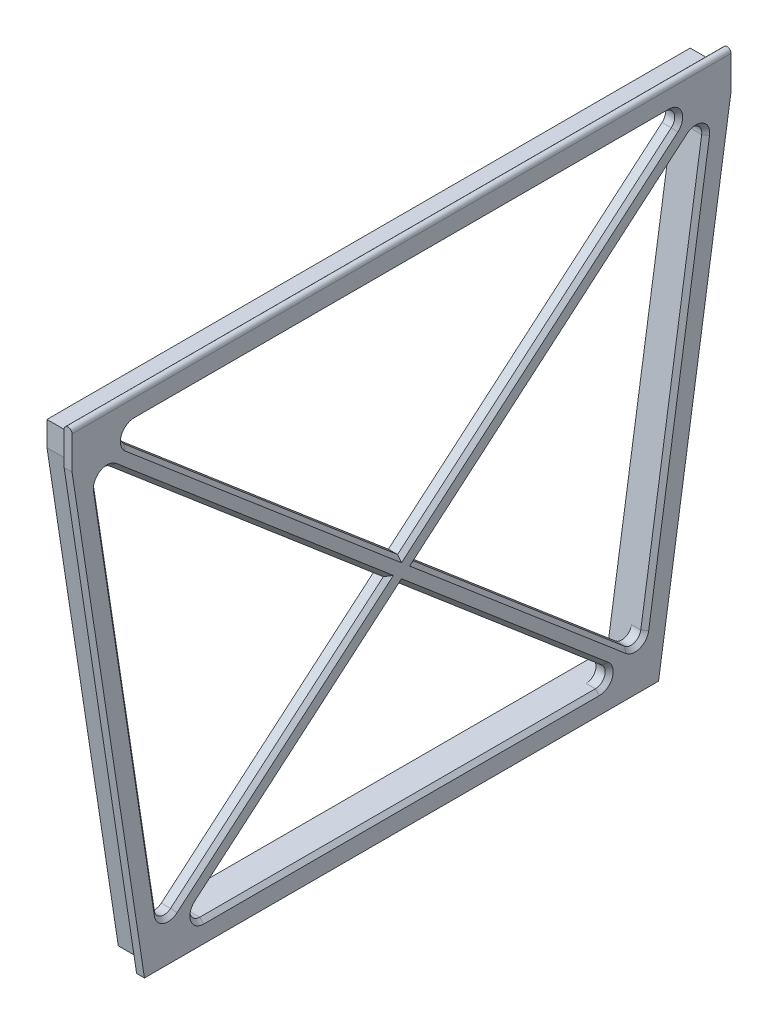
from build123d import *

# Parameters (mm, degrees)
EXTRUDE_THIN1_DEPTH          = 5
EXTRUDE_THIN2_DEPTH          = 2
CUT_EXTRUDE_THIN1_DEPTH      = 1
CUT_EXTRUDE_THIN1_DEPTH_BACK = 3.8
BOSS_EXTRUDE1_DEPTH          = 100
FILLET1_R                    = 1.5
CHAMFER1_SIZE                = 0.6


with BuildPart() as part:
    # Sketch1 → Extrude-Thin1 (new body)
    with BuildSketch(Plane(origin=(0, 0, 0), x_dir=(0, 0, -1), z_dir=(1, 0, 0))):
        Polygon((50, 77), (-50, 77), (-50, 72), (-39, 0), (39, 0), (50, 72), align=None)
        Polygon((46.8, 73.8), (-46.8, 73.8), (-46.8, 72.243034455), (-36.251758625, 3.2), (36.251758625, 3.2), (46.8, 72.243034455), align=None, mode=Mode.SUBTRACT)
    extrude(amount=EXTRUDE_THIN1_DEPTH)

    # Sketch3 → Extrude-Thin2 (add)
    with BuildSketch(Plane(origin=(5, 0, 0), x_dir=(0, 0, -1), z_dir=(1, 0, 0))):
        Polygon((-47.706752564, 72.733323016), (35.345006061, 2.133323016), (37.158511189, 4.266676984), (-45.893247436, 74.866676984), align=None)
        Polygon((45.893247436, 74.866676984), (-37.158511189, 4.266676984), (-35.345006061, 2.133323016), (47.706752564, 72.733323016), align=None)
    extrude(amount=-EXTRUDE_THIN2_DEPTH)

    # Sketch4 → Cut-Extrude-Thin1 (cut, two sides)
    with BuildSketch(Plane.ZY) as cut_extrude_thin1_sk:
        Polygon((50, 77), (50, 72), (39, 0), (-39, 0), (-50, 72), (-50, 77), align=None)
        Polygon((48.8, 75.8), (48.8, 72.091137921), (37.969409484, 1.2), (-37.969409484, 1.2), (-48.8, 72.091137921), (-48.8, 75.8), align=None, mode=Mode.SUBTRACT)
    extrude(amount=CUT_EXTRUDE_THIN1_DEPTH, mode=Mode.SUBTRACT)
    extrude(cut_extrude_thin1_sk.sketch, amount=-CUT_EXTRUDE_THIN1_DEPTH_BACK, mode=Mode.SUBTRACT)

    # Sketch5 → Boss-Extrude1 (add)
    with BuildSketch(Plane(origin=(0, 0, -50), x_dir=(-1, 0, 0), z_dir=(0, 0, -1))):
        with BuildLine():
            Line((-5, 77), (-3.8, 77))
            ThreePointArc((-3.8, 77), (-4.4, 77.6), (-5, 77))
        make_face()
    extrude(amount=-BOSS_EXTRUDE1_DEPTH)

    # Fillet1
    fillet1_edges = [part.edges().sort_by_distance(p)[0] for p in [
        (4, 73.8, -44.638440079),
        (4, 73.8, 44.638440079),
        (4, 71.92064886, -46.750746645),
        (4, 4.826274454, -36.500217222),
        (4, 3.2, 34.090198704),
        (4, 3.2, -34.090198704),
        (4, 4.826274454, 36.500217222),
        (4, 71.92064886, 46.750746645),
    ]]
    fillet(fillet1_edges, radius=FILLET1_R)

    # Chamfer1
    chamfer1_edges = [part.edges().sort_by_distance(p)[0] for p in [
        (5, 37.716457047, 41.525106229),
        (5, 3.2, 0),
        (5, 51.667563114, 22.92561366),
        (5, 73.8, 0),
        (5, 53.505615047, 20.764723924),
        (5, 37.716457047, -41.525106229),
        (5, 51.667563114, -22.92561366),
        (5, 53.505615047, -20.764723924),
        (5, 6.30509587, 35.948092357),
        (5, 4.18245884, 31.417574766),
        (5, 69.485539395, 45.392056481),
        (5, 72.81754116, 41.965816141),
        (5, 69.485539395, -45.392056481),
        (5, 72.81754116, -41.965816141),
        (5, 4.18245884, -31.417574766),
        (5, 6.30509587, -35.948092357),
        (5, 20.292048094, -18.306737062),
        (5, 19.011001017, -15.490603236),
        (5, 20.292048094, 18.306737062),
        (5, 19.011001017, 15.490603236),
    ]]
    chamfer(chamfer1_edges, length=CHAMFER1_SIZE)


solid = part.part
